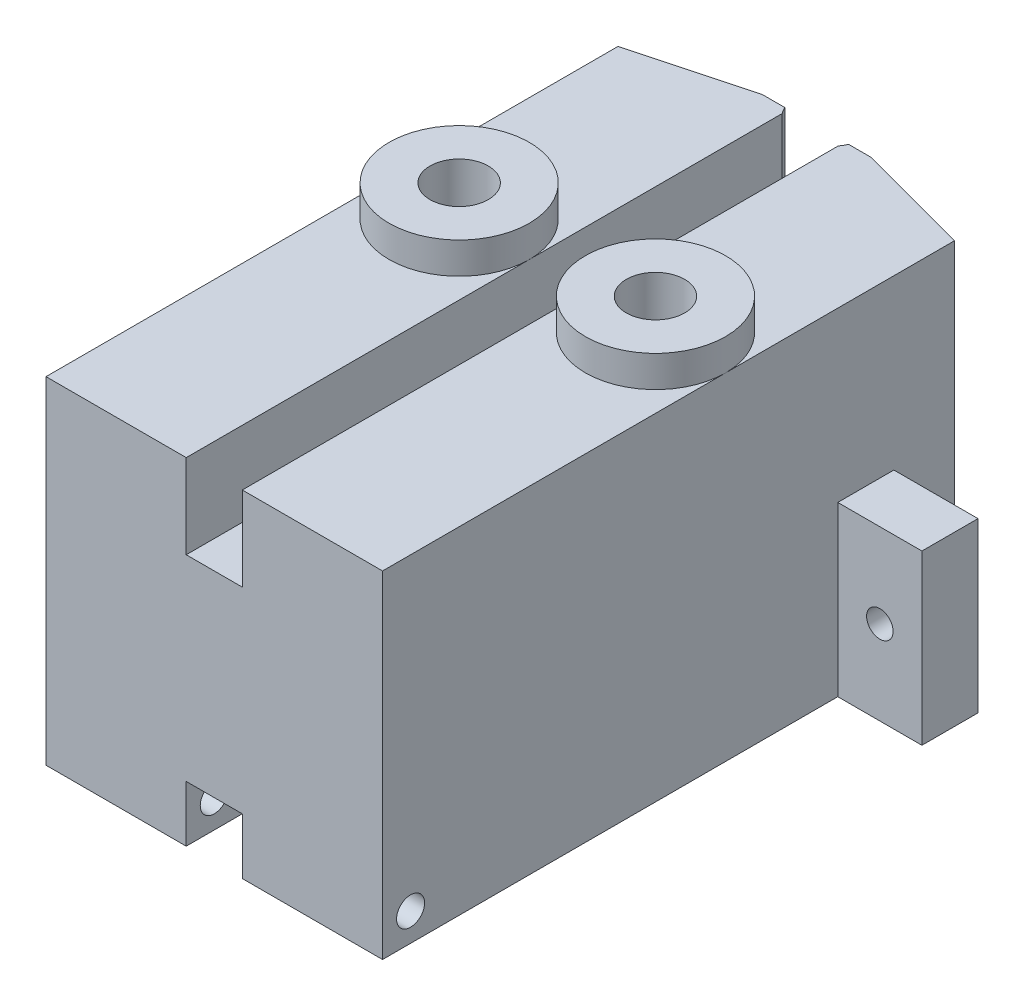
from build123d import *

# Parameters (mm, degrees)
SKETCH1_W                = 38.1
SKETCH1_H                = 19.05
BOSS_EXTRUDE1_DEPTH      = 9.525
CUT_EXTRUDE1_DEPTH       = 10.525
CUT_EXTRUDE1_DEPTH_BACK  = 10.525
SKETCH3_R                = 1.984375
CUT_EXTRUDE2_DEPTH       = 10.525
CUT_EXTRUDE2_DEPTH_BACK  = 10.525
SKETCH4_W                = 3.175
SKETCH4_H                = 4.7625
SKETCH4_H_2              = 3.175
CUT_EXTRUDE3_DEPTH       = 20.05
CUT_EXTRUDE3_DEPTH_BACK  = 20.05
CUT_EXTRUDE9_START       = -2.38125
SKETCH11_R               = 3.683
CUT_EXTRUDE9_DEPTH       = 6.35
SKETCH12_W               = 6.35
SKETCH12_H               = 3.175
CUT_EXTRUDE10_DEPTH      = 10.525
CUT_EXTRUDE10_DEPTH_BACK = 10.525
SKETCH14_R               = 0.79375
CUT_EXTRUDE11_DEPTH      = 10.525
CUT_EXTRUDE11_DEPTH_BACK = 10.525
CUT_EXTRUDE12_DEPTH      = 4.7625
SKETCH16_W               = 3.175
SKETCH16_H               = 9.525
BOSS_EXTRUDE2_DEPTH      = 4.7625
SKETCH17_W               = 3.175
SKETCH17_H               = 9.525
BOSS_EXTRUDE3_DEPTH      = 4.7625
SKETCH18_R               = 0.7493
CUT_EXTRUDE13_DEPTH      = 29.943380657
SKETCH19_R               = 3.96875
BOSS_EXTRUDE4_DEPTH      = 1.778
SKETCH20_R               = 1.651
CUT_EXTRUDE14_DEPTH      = 21.828


with BuildPart() as part:
    # Sketch1 → Boss-Extrude1 (new body, symmetric)
    with BuildSketch(Plane(origin=(0, 0, 0), x_dir=(0, 0, -1), z_dir=(1, 0, 0))):
        Rectangle(SKETCH1_W, SKETCH1_H)
    extrude(amount=BOSS_EXTRUDE1_DEPTH, both=True)

    # Sketch2 → Cut-Extrude1 (cut, two sides)
    with BuildSketch(Plane(origin=(0, 0, 0), x_dir=(1, 0, 0), z_dir=(0, 1, 0))) as cut_extrude1_sk:
        with BuildLine():
            Line((91.748361933, -8.708899487), (9.525, 13.322783942))
            Line((9.525, 13.322783942), (3.066814498, 15.053249532))
            ThreePointArc((3.066814498, 15.053249532), (0, 19.05), (-3.066814498, 15.053249532))
            Line((-3.066814498, 15.053249532), (-9.525, 13.322783942))
            Line((-9.525, 13.322783942), (-91.748361933, -8.708899487))
            Line((-91.748361933, -8.708899487), (-91.748361933, 161.538876678))
            Line((-91.748361933, 161.538876678), (91.748361933, 161.538876678))
            Line((91.748361933, 161.538876678), (91.748361933, -8.708899487))
        make_face()
    extrude(amount=CUT_EXTRUDE1_DEPTH, mode=Mode.SUBTRACT)
    extrude(cut_extrude1_sk.sketch, amount=-CUT_EXTRUDE1_DEPTH_BACK, mode=Mode.SUBTRACT)

    # Sketch3 → Cut-Extrude2 (cut, two sides)
    with BuildSketch(Plane(origin=(0, 0, 0), x_dir=(1, 0, 0), z_dir=(0, 1, 0))) as cut_extrude2_sk:
        with Locations((0, 15.875)):
            Circle(SKETCH3_R)
    extrude(amount=CUT_EXTRUDE2_DEPTH, mode=Mode.SUBTRACT)
    extrude(cut_extrude2_sk.sketch, amount=-CUT_EXTRUDE2_DEPTH_BACK, mode=Mode.SUBTRACT)

    # Sketch4 → Cut-Extrude3 (cut, two sides)
    with BuildSketch(Plane.XY) as cut_extrude3_sk:
        with Locations((0, 7.14375)):
            Rectangle(SKETCH4_W, SKETCH4_H)
        with Locations((0, -7.9375)):
            Rectangle(SKETCH4_W, SKETCH4_H_2)
    extrude(amount=CUT_EXTRUDE3_DEPTH, mode=Mode.SUBTRACT)
    extrude(cut_extrude3_sk.sketch, amount=-CUT_EXTRUDE3_DEPTH_BACK, mode=Mode.SUBTRACT)

    # Sketch11 → Cut-Extrude9 (cut)
    with BuildSketch(Plane(origin=(0, 4.7625, 0), x_dir=(1, 0, 0), z_dir=(0, 1, 0)).offset(CUT_EXTRUDE9_START)):
        with Locations((0, 15.875)):
            Circle(SKETCH11_R)
    extrude(amount=-CUT_EXTRUDE9_DEPTH, mode=Mode.SUBTRACT)

    # Sketch12 → Cut-Extrude10 (cut, two sides)
    with BuildSketch(Plane(origin=(0, 0, 0), x_dir=(0, 0, -1), z_dir=(1, 0, 0))) as cut_extrude10_sk:
        with Locations((15.449630657, -7.9375)):
            Rectangle(SKETCH12_W, SKETCH12_H)
    extrude(amount=CUT_EXTRUDE10_DEPTH, mode=Mode.SUBTRACT)
    extrude(cut_extrude10_sk.sketch, amount=-CUT_EXTRUDE10_DEPTH_BACK, mode=Mode.SUBTRACT)

    # Sketch14 → Cut-Extrude11 (cut, two sides)
    with BuildSketch(Plane(origin=(0, 0, 0), x_dir=(0, 0, -1), z_dir=(1, 0, 0))) as cut_extrude11_sk:
        with Locations((-17.4625, -7.9375)):
            Circle(SKETCH14_R)
        with Locations((10.687130657, -7.9375)):
            Circle(SKETCH14_R)
    extrude(amount=CUT_EXTRUDE11_DEPTH, mode=Mode.SUBTRACT)
    extrude(cut_extrude11_sk.sketch, amount=-CUT_EXTRUDE11_DEPTH_BACK, mode=Mode.SUBTRACT)

    # Sketch15 → Cut-Extrude12 (cut)
    with BuildSketch(Plane(origin=(0, 9.525, 0), x_dir=(1, 0, 0), z_dir=(0, 1, 0))):
        Polygon((-9.525, 13.322783942), (-3.066814498, 15.053249532), (3.066814498, 15.053249532), (9.525, 13.322783942), (9.525, 19.05), (-9.525, 19.05), align=None)
    extrude(amount=-CUT_EXTRUDE12_DEPTH, mode=Mode.SUBTRACT)

    # Sketch16 → Boss-Extrude2 (add)
    with BuildSketch(Plane(origin=(9.525, 0, 0), x_dir=(0, 0, -1), z_dir=(1, 0, 0))):
        with Locations((8.305880657, -4.7625)):
            Rectangle(SKETCH16_W, SKETCH16_H)
    extrude(amount=BOSS_EXTRUDE2_DEPTH)

    # Sketch17 → Boss-Extrude3 (add)
    with BuildSketch(Plane.ZY.offset(9.525)):
        with Locations((-8.305880657, -4.7625)):
            Rectangle(SKETCH17_W, SKETCH17_H)
    extrude(amount=BOSS_EXTRUDE3_DEPTH)

    # Sketch18 → Cut-Extrude13 (cut, through all)
    with BuildSketch(Plane(origin=(0, 0, -9.893380657), x_dir=(-1, 0, 0), z_dir=(0, 0, -1))):
        with Locations((-11.90625, -4.7625)):
            Circle(SKETCH18_R)
        with Locations((11.90625, -4.7625)):
            Circle(SKETCH18_R)
    extrude(amount=-CUT_EXTRUDE13_DEPTH, mode=Mode.SUBTRACT)

    # Sketch19 → Boss-Extrude4 (add)
    with BuildSketch(Plane(origin=(0, 9.525, 0), x_dir=(1, 0, 0), z_dir=(0, 1, 0))):
        with Locations((-5.55625, 0.368380657)):
            Circle(SKETCH19_R)
        with Locations((5.55625, 0.368380657)):
            Circle(SKETCH19_R)
    extrude(amount=BOSS_EXTRUDE4_DEPTH)

    # Sketch20 → Cut-Extrude14 (cut, through all)
    with BuildSketch(Plane(origin=(0, 11.303, 0), x_dir=(1, 0, 0), z_dir=(0, 1, 0))):
        with Locations((-5.55625, 0.368380657)):
            Circle(SKETCH20_R)
        with Locations((5.55625, 0.368380657)):
            Circle(SKETCH20_R)
    extrude(amount=-CUT_EXTRUDE14_DEPTH, mode=Mode.SUBTRACT)


solid = part.part
